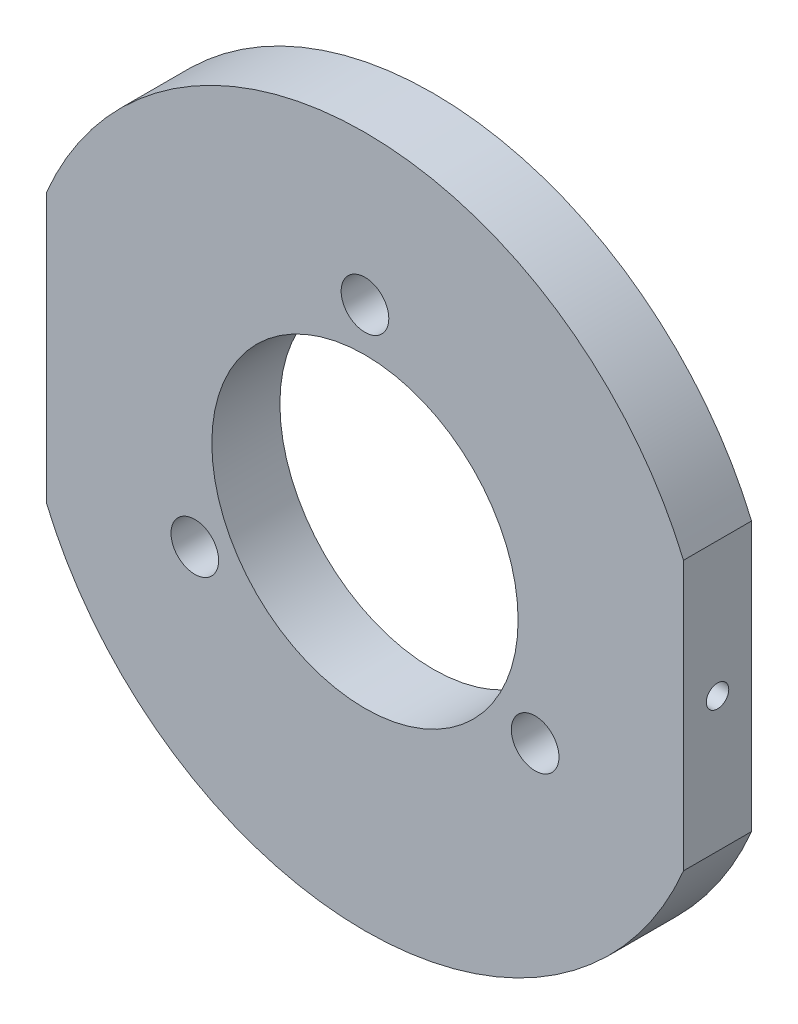
from build123d import *

# Parameters (mm, degrees)
SKETCH1_R           = 22.5
SKETCH1_R_2         = 3.5
BOSS_EXTRUDE1_DEPTH = 10


with BuildPart() as part:
    # Sketch1 → Boss-Extrude1 (new body)
    with BuildSketch(Plane.XY):
        with BuildLine():
            Line((46.8, 19.758542456), (46.8, -19.758542456))
            ThreePointArc((46.8, -19.758542456), (0, -50.8), (-46.8, -19.758542456))
            Line((-46.8, -19.758542456), (-46.8, 19.758542456))
            ThreePointArc((-46.8, 19.758542456), (0, 50.8), (46.8, 19.758542456))
        make_face()
        Circle(SKETCH1_R, mode=Mode.SUBTRACT)
        with Locations((0, 28.867513459)):
            Circle(SKETCH1_R_2, mode=Mode.SUBTRACT)
        with Locations((25, -14.43375673)):
            Circle(SKETCH1_R_2, mode=Mode.SUBTRACT)
        with Locations((-25, -14.43375673)):
            Circle(SKETCH1_R_2, mode=Mode.SUBTRACT)
    extrude(amount=BOSS_EXTRUDE1_DEPTH)

    # Sketch4 → M4x0.7 Tapped Hole1 (revolve, cut)
    with BuildSketch(Plane(origin=(46.8, 0, 5), x_dir=(0, 0, -1), z_dir=(0, 1, 0))):
        Polygon((0, 0), (0, 15.991420021), (1.65, 15), (1.65, 0), align=None)
    m4x0_7_tapped_hole1 = revolve(axis=Axis((53.15, 0, 5), (-1, 0, 0)), mode=Mode.SUBTRACT)

    # Mirror1: M4x0.7 Tapped Hole1 across plane
    add(m4x0_7_tapped_hole1.mirror(Plane(origin=(0, 0, 0), x_dir=(0, 0, 1), z_dir=(1, 0, 0))), mode=Mode.SUBTRACT)


solid = part.part
